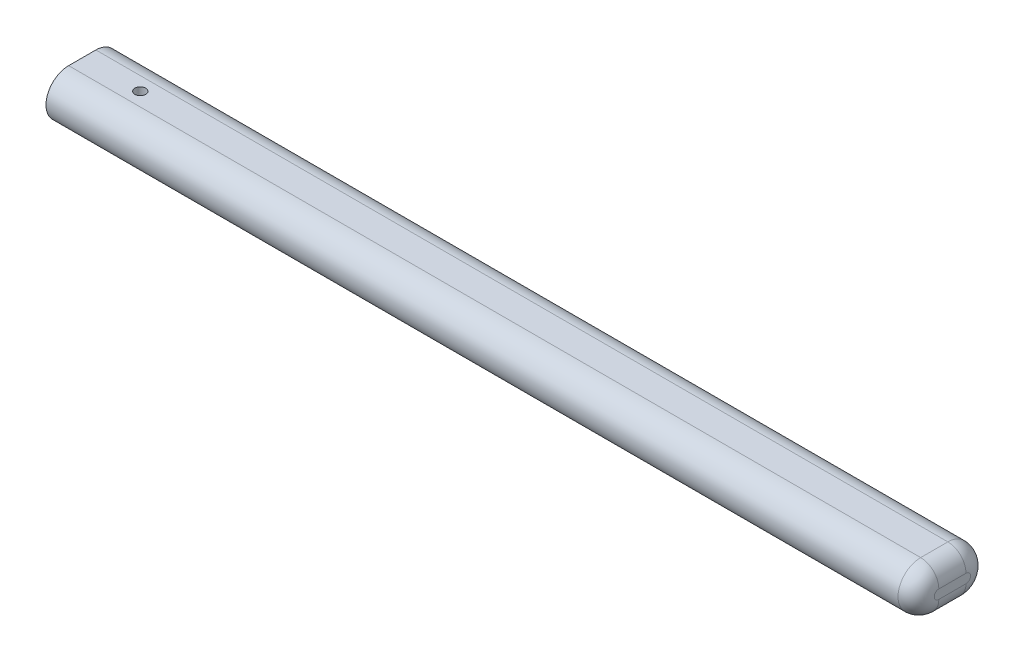
from build123d import *

# Parameters (mm, degrees)
SALIENTE_EXTRUIR1_DEPTH = 480
REDONDEO1_R             = 10
CROQUIS2_R              = 3
CORTAR_EXTRUIR1_DEPTH   = 25


with BuildPart() as part:
    # Croquis1 → Saliente-Extruir1 (new body)
    with BuildSketch(Plane(origin=(0, 0, 0), x_dir=(0, 0, -1), z_dir=(1, 0, 0))):
        with BuildLine():
            Line((0, 12.5), (15, 12.5))
            ThreePointArc((15, 12.5), (27.5, 0), (15, -12.5))
            Line((15, -12.5), (0, -12.5))
            ThreePointArc((0, -12.5), (-12.5, 0), (0, 12.5))
        make_face()
    extrude(amount=SALIENTE_EXTRUIR1_DEPTH)

    # Redondeo1
    redondeo1_edges = [part.edges().sort_by_distance(p)[0] for p in [
        (480, 0, -27.5),
        (480, 12.5, -7.5),
        (480, 0, 12.5),
        (480, -12.5, -7.5),
    ]]
    fillet(redondeo1_edges, radius=REDONDEO1_R)

    # Croquis2 → Cortar-Extruir1 (cut)
    with BuildSketch(Plane(origin=(0, 12.5, 0), x_dir=(1, 0, 0), z_dir=(0, 1, 0))):
        with Locations((32, 7.5)):
            Circle(CROQUIS2_R)
    extrude(amount=-CORTAR_EXTRUIR1_DEPTH, mode=Mode.SUBTRACT)


solid = part.part
